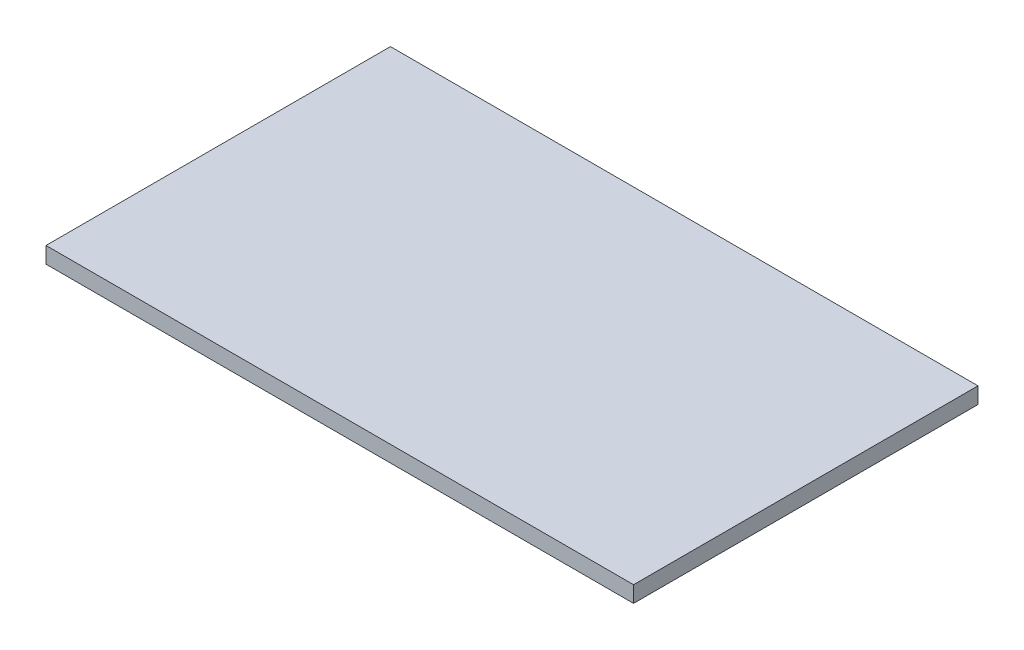
from build123d import *

# Parameters (mm, degrees)
SKETCH1_W           = 145
SKETCH1_H           = 85
BOSS_EXTRUDE1_DEPTH = 4


with BuildPart() as part:
    # Sketch1 → Boss-Extrude1 (new body)
    with BuildSketch(Plane(origin=(0, 0, 0), x_dir=(1, 0, 0), z_dir=(0, 1, 0))):
        Rectangle(SKETCH1_W, SKETCH1_H)
    extrude(amount=BOSS_EXTRUDE1_DEPTH)


solid = part.part
